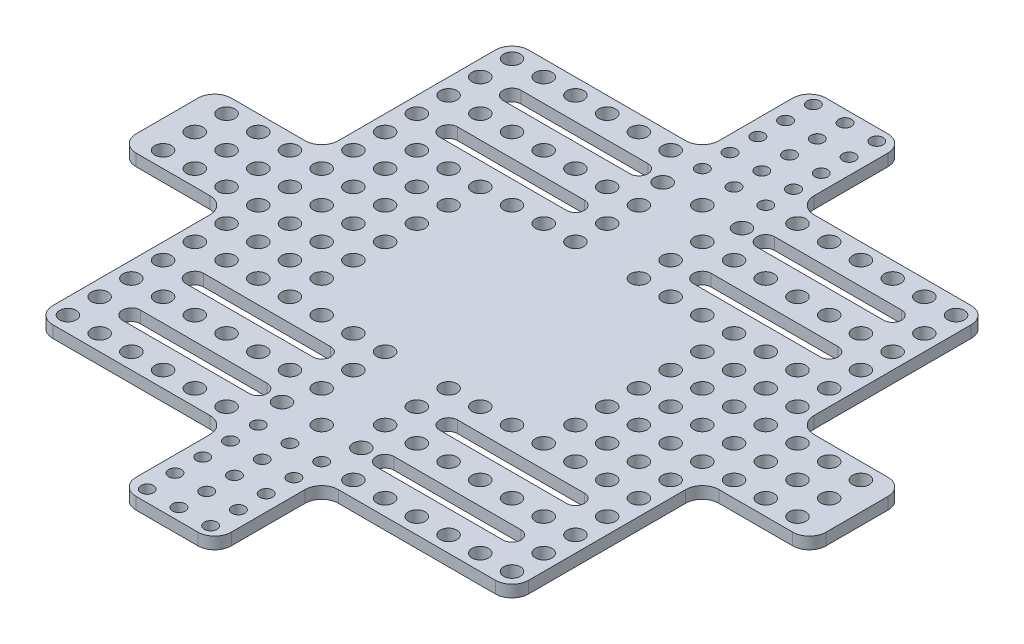
from build123d import *

# Parameters (mm, degrees)
SKETCH_1_R      = 1.6
SKETCH_1_R_2    = 2.1
EXTRUDE_1_DEPTH = 3
FILLET_1_R      = 4.2


with BuildPart() as part:
    # 草图1 → 凸台-拉伸1 (new body)
    with BuildSketch(Plane(origin=(0, 0, 0), x_dir=(1, 0, 0), z_dir=(0, 1, 0))):
        Polygon((87, -12), (60, -12), (60, -60), (12, -60), (12, -87), (-12, -87), (-12, -60), (-60, -60), (-60, -12), (-87, -12), (-87, 12), (-60, 12), (-60, 60), (-12, 60), (-12, 87), (12, 87), (12, 60), (60, 60), (60, 12), (87, 12), align=None)
        with Locations((0, 56)):
            Circle(SKETCH_1_R, mode=Mode.SUBTRACT)
        with Locations((-56, 56)):
            Circle(SKETCH_1_R_2, mode=Mode.SUBTRACT)
        with Locations((-48, 56)):
            Circle(SKETCH_1_R_2, mode=Mode.SUBTRACT)
        with Locations((-40, 56)):
            Circle(SKETCH_1_R_2, mode=Mode.SUBTRACT)
        with Locations((-32, 56)):
            Circle(SKETCH_1_R_2, mode=Mode.SUBTRACT)
        with Locations((-24, 56)):
            Circle(SKETCH_1_R_2, mode=Mode.SUBTRACT)
        with Locations((-16, 56)):
            Circle(SKETCH_1_R_2, mode=Mode.SUBTRACT)
        with Locations((-8, 56)):
            Circle(SKETCH_1_R, mode=Mode.SUBTRACT)
        with Locations((8, 56)):
            Circle(SKETCH_1_R, mode=Mode.SUBTRACT)
        with Locations((0, 63)):
            Circle(SKETCH_1_R, mode=Mode.SUBTRACT)
        with Locations((-8, 63)):
            Circle(SKETCH_1_R, mode=Mode.SUBTRACT)
        with Locations((8, 63)):
            Circle(SKETCH_1_R, mode=Mode.SUBTRACT)
        with Locations((0, 70)):
            Circle(SKETCH_1_R, mode=Mode.SUBTRACT)
        with Locations((-8, 70)):
            Circle(SKETCH_1_R, mode=Mode.SUBTRACT)
        with Locations((8, 70)):
            Circle(SKETCH_1_R, mode=Mode.SUBTRACT)
        with Locations((0, 77)):
            Circle(SKETCH_1_R, mode=Mode.SUBTRACT)
        with Locations((-8, 77)):
            Circle(SKETCH_1_R, mode=Mode.SUBTRACT)
        with Locations((8, 77)):
            Circle(SKETCH_1_R, mode=Mode.SUBTRACT)
        with Locations((0, 84)):
            Circle(SKETCH_1_R, mode=Mode.SUBTRACT)
        with Locations((-8, 84)):
            Circle(SKETCH_1_R, mode=Mode.SUBTRACT)
        with Locations((8, 84)):
            Circle(SKETCH_1_R, mode=Mode.SUBTRACT)
        with Locations((0, 48)):
            Circle(SKETCH_1_R_2, mode=Mode.SUBTRACT)
        with Locations((-10, 48)):
            Circle(SKETCH_1_R_2, mode=Mode.SUBTRACT)
        with Locations((10, 48)):
            Circle(SKETCH_1_R_2, mode=Mode.SUBTRACT)
        with Locations((-56, 16)):
            Circle(SKETCH_1_R_2, mode=Mode.SUBTRACT)
        with Locations((-56, 24)):
            Circle(SKETCH_1_R_2, mode=Mode.SUBTRACT)
        with Locations((-56, 32)):
            Circle(SKETCH_1_R_2, mode=Mode.SUBTRACT)
        with Locations((-56, 40)):
            Circle(SKETCH_1_R_2, mode=Mode.SUBTRACT)
        with Locations((-56, 48)):
            Circle(SKETCH_1_R_2, mode=Mode.SUBTRACT)
        with Locations((-48, 16)):
            Circle(SKETCH_1_R_2, mode=Mode.SUBTRACT)
        with Locations((-40, 16)):
            Circle(SKETCH_1_R_2, mode=Mode.SUBTRACT)
        with Locations((-32, 16)):
            Circle(SKETCH_1_R_2, mode=Mode.SUBTRACT)
        with Locations((-48, 8)):
            Circle(SKETCH_1_R_2, mode=Mode.SUBTRACT)
        with Locations((-40, 8)):
            Circle(SKETCH_1_R_2, mode=Mode.SUBTRACT)
        with Locations((-32, 8)):
            Circle(SKETCH_1_R_2, mode=Mode.SUBTRACT)
        with Locations((-48, 0)):
            Circle(SKETCH_1_R_2, mode=Mode.SUBTRACT)
        with Locations((-40, 0)):
            Circle(SKETCH_1_R_2, mode=Mode.SUBTRACT)
        with Locations((-32, 0)):
            Circle(SKETCH_1_R_2, mode=Mode.SUBTRACT)
        with Locations((-48, -8)):
            Circle(SKETCH_1_R_2, mode=Mode.SUBTRACT)
        with Locations((-40, -8)):
            Circle(SKETCH_1_R_2, mode=Mode.SUBTRACT)
        with Locations((-32, -8)):
            Circle(SKETCH_1_R_2, mode=Mode.SUBTRACT)
        with Locations((-48, -16)):
            Circle(SKETCH_1_R_2, mode=Mode.SUBTRACT)
        with Locations((-40, -16)):
            Circle(SKETCH_1_R_2, mode=Mode.SUBTRACT)
        with Locations((-32, -16)):
            Circle(SKETCH_1_R_2, mode=Mode.SUBTRACT)
        with Locations((-56, 8)):
            Circle(SKETCH_1_R_2, mode=Mode.SUBTRACT)
        with Locations((-56, 0)):
            Circle(SKETCH_1_R_2, mode=Mode.SUBTRACT)
        with Locations((-56, -8)):
            Circle(SKETCH_1_R_2, mode=Mode.SUBTRACT)
        with Locations((-56, -16)):
            Circle(SKETCH_1_R_2, mode=Mode.SUBTRACT)
        with Locations((56, -16)):
            Circle(SKETCH_1_R_2, mode=Mode.SUBTRACT)
        with Locations((56, -8)):
            Circle(SKETCH_1_R_2, mode=Mode.SUBTRACT)
        with Locations((56, 0)):
            Circle(SKETCH_1_R_2, mode=Mode.SUBTRACT)
        with Locations((56, 8)):
            Circle(SKETCH_1_R_2, mode=Mode.SUBTRACT)
        with Locations((32, -16)):
            Circle(SKETCH_1_R_2, mode=Mode.SUBTRACT)
        with Locations((40, -16)):
            Circle(SKETCH_1_R_2, mode=Mode.SUBTRACT)
        with Locations((48, -16)):
            Circle(SKETCH_1_R_2, mode=Mode.SUBTRACT)
        with Locations((32, -8)):
            Circle(SKETCH_1_R_2, mode=Mode.SUBTRACT)
        with Locations((40, -8)):
            Circle(SKETCH_1_R_2, mode=Mode.SUBTRACT)
        with Locations((48, -8)):
            Circle(SKETCH_1_R_2, mode=Mode.SUBTRACT)
        with Locations((32, 0)):
            Circle(SKETCH_1_R_2, mode=Mode.SUBTRACT)
        with Locations((40, 0)):
            Circle(SKETCH_1_R_2, mode=Mode.SUBTRACT)
        with Locations((48, 0)):
            Circle(SKETCH_1_R_2, mode=Mode.SUBTRACT)
        with Locations((32, 8)):
            Circle(SKETCH_1_R_2, mode=Mode.SUBTRACT)
        with Locations((40, 8)):
            Circle(SKETCH_1_R_2, mode=Mode.SUBTRACT)
        with Locations((48, 8)):
            Circle(SKETCH_1_R_2, mode=Mode.SUBTRACT)
        with Locations((32, 16)):
            Circle(SKETCH_1_R_2, mode=Mode.SUBTRACT)
        with Locations((40, 16)):
            Circle(SKETCH_1_R_2, mode=Mode.SUBTRACT)
        with Locations((48, 16)):
            Circle(SKETCH_1_R_2, mode=Mode.SUBTRACT)
        with Locations((56, 16)):
            Circle(SKETCH_1_R_2, mode=Mode.SUBTRACT)
        with Locations((-48, 40)):
            Circle(SKETCH_1_R_2, mode=Mode.SUBTRACT)
        with Locations((-40, 40)):
            Circle(SKETCH_1_R_2, mode=Mode.SUBTRACT)
        with Locations((-32, 40)):
            Circle(SKETCH_1_R_2, mode=Mode.SUBTRACT)
        with Locations((-24, 40)):
            Circle(SKETCH_1_R_2, mode=Mode.SUBTRACT)
        with Locations((-16, 40)):
            Circle(SKETCH_1_R_2, mode=Mode.SUBTRACT)
        with Locations((-8, 40)):
            Circle(SKETCH_1_R_2, mode=Mode.SUBTRACT)
        with Locations((-16, 24)):
            Circle(SKETCH_1_R_2, mode=Mode.SUBTRACT)
        with Locations((-24, 24)):
            Circle(SKETCH_1_R_2, mode=Mode.SUBTRACT)
        with Locations((-32, 24)):
            Circle(SKETCH_1_R_2, mode=Mode.SUBTRACT)
        with Locations((-48, 24)):
            Circle(SKETCH_1_R_2, mode=Mode.SUBTRACT)
        with Locations((-40, 24)):
            Circle(SKETCH_1_R_2, mode=Mode.SUBTRACT)
        with Locations((-8, 24)):
            Circle(SKETCH_1_R_2, mode=Mode.SUBTRACT)
        with Locations((8, 24)):
            Circle(SKETCH_1_R_2, mode=Mode.SUBTRACT)
        with Locations((16, 24)):
            Circle(SKETCH_1_R_2, mode=Mode.SUBTRACT)
        with Locations((24, 24)):
            Circle(SKETCH_1_R_2, mode=Mode.SUBTRACT)
        with Locations((32, 24)):
            Circle(SKETCH_1_R_2, mode=Mode.SUBTRACT)
        with Locations((40, 24)):
            Circle(SKETCH_1_R_2, mode=Mode.SUBTRACT)
        with Locations((48, 24)):
            Circle(SKETCH_1_R_2, mode=Mode.SUBTRACT)
        with Locations((56, 24)):
            Circle(SKETCH_1_R_2, mode=Mode.SUBTRACT)
        with Locations((56, 32)):
            Circle(SKETCH_1_R_2, mode=Mode.SUBTRACT)
        with Locations((8, 40)):
            Circle(SKETCH_1_R_2, mode=Mode.SUBTRACT)
        with Locations((16, 40)):
            Circle(SKETCH_1_R_2, mode=Mode.SUBTRACT)
        with Locations((24, 40)):
            Circle(SKETCH_1_R_2, mode=Mode.SUBTRACT)
        with Locations((32, 40)):
            Circle(SKETCH_1_R_2, mode=Mode.SUBTRACT)
        with Locations((40, 40)):
            Circle(SKETCH_1_R_2, mode=Mode.SUBTRACT)
        with Locations((48, 40)):
            Circle(SKETCH_1_R_2, mode=Mode.SUBTRACT)
        with Locations((56, 40)):
            Circle(SKETCH_1_R_2, mode=Mode.SUBTRACT)
        with Locations((56, 48)):
            Circle(SKETCH_1_R_2, mode=Mode.SUBTRACT)
        with Locations((16, 56)):
            Circle(SKETCH_1_R_2, mode=Mode.SUBTRACT)
        with Locations((24, 56)):
            Circle(SKETCH_1_R_2, mode=Mode.SUBTRACT)
        with Locations((32, 56)):
            Circle(SKETCH_1_R_2, mode=Mode.SUBTRACT)
        with Locations((40, 56)):
            Circle(SKETCH_1_R_2, mode=Mode.SUBTRACT)
        with Locations((48, 56)):
            Circle(SKETCH_1_R_2, mode=Mode.SUBTRACT)
        with Locations((56, 56)):
            Circle(SKETCH_1_R_2, mode=Mode.SUBTRACT)
        with Locations((8, -77)):
            Circle(SKETCH_1_R, mode=Mode.SUBTRACT)
        with Locations((8, -84)):
            Circle(SKETCH_1_R, mode=Mode.SUBTRACT)
        with Locations((0, -84)):
            Circle(SKETCH_1_R, mode=Mode.SUBTRACT)
        with Locations((-8, -84)):
            Circle(SKETCH_1_R, mode=Mode.SUBTRACT)
        with Locations((-8, -77)):
            Circle(SKETCH_1_R, mode=Mode.SUBTRACT)
        with Locations((0, -77)):
            Circle(SKETCH_1_R, mode=Mode.SUBTRACT)
        with Locations((8, -70)):
            Circle(SKETCH_1_R, mode=Mode.SUBTRACT)
        with Locations((0, -70)):
            Circle(SKETCH_1_R, mode=Mode.SUBTRACT)
        with Locations((-8, -70)):
            Circle(SKETCH_1_R, mode=Mode.SUBTRACT)
        with Locations((-8, -63)):
            Circle(SKETCH_1_R, mode=Mode.SUBTRACT)
        with Locations((0, -63)):
            Circle(SKETCH_1_R, mode=Mode.SUBTRACT)
        with Locations((8, -63)):
            Circle(SKETCH_1_R, mode=Mode.SUBTRACT)
        with Locations((24, -56)):
            Circle(SKETCH_1_R_2, mode=Mode.SUBTRACT)
        with Locations((16, -56)):
            Circle(SKETCH_1_R_2, mode=Mode.SUBTRACT)
        with Locations((8, -56)):
            Circle(SKETCH_1_R, mode=Mode.SUBTRACT)
        with Locations((0, -56)):
            Circle(SKETCH_1_R, mode=Mode.SUBTRACT)
        with Locations((-8, -56)):
            Circle(SKETCH_1_R, mode=Mode.SUBTRACT)
        with Locations((-16, -56)):
            Circle(SKETCH_1_R_2, mode=Mode.SUBTRACT)
        with Locations((-24, -56)):
            Circle(SKETCH_1_R_2, mode=Mode.SUBTRACT)
        with Locations((-32, -56)):
            Circle(SKETCH_1_R_2, mode=Mode.SUBTRACT)
        with Locations((-40, -56)):
            Circle(SKETCH_1_R_2, mode=Mode.SUBTRACT)
        with Locations((-48, -56)):
            Circle(SKETCH_1_R_2, mode=Mode.SUBTRACT)
        with Locations((-56, -56)):
            Circle(SKETCH_1_R_2, mode=Mode.SUBTRACT)
        with Locations((-56, -48)):
            Circle(SKETCH_1_R_2, mode=Mode.SUBTRACT)
        with Locations((10, -48)):
            Circle(SKETCH_1_R_2, mode=Mode.SUBTRACT)
        with Locations((0, -48)):
            Circle(SKETCH_1_R_2, mode=Mode.SUBTRACT)
        with Locations((-10, -48)):
            Circle(SKETCH_1_R_2, mode=Mode.SUBTRACT)
        with Locations((32, -56)):
            Circle(SKETCH_1_R_2, mode=Mode.SUBTRACT)
        with Locations((40, -56)):
            Circle(SKETCH_1_R_2, mode=Mode.SUBTRACT)
        with Locations((48, -56)):
            Circle(SKETCH_1_R_2, mode=Mode.SUBTRACT)
        with Locations((56, -56)):
            Circle(SKETCH_1_R_2, mode=Mode.SUBTRACT)
        with Locations((56, -48)):
            Circle(SKETCH_1_R_2, mode=Mode.SUBTRACT)
        with Locations((56, -40)):
            Circle(SKETCH_1_R_2, mode=Mode.SUBTRACT)
        with Locations((48, -40)):
            Circle(SKETCH_1_R_2, mode=Mode.SUBTRACT)
        with Locations((40, -40)):
            Circle(SKETCH_1_R_2, mode=Mode.SUBTRACT)
        with Locations((32, -40)):
            Circle(SKETCH_1_R_2, mode=Mode.SUBTRACT)
        with Locations((24, -40)):
            Circle(SKETCH_1_R_2, mode=Mode.SUBTRACT)
        with Locations((16, -40)):
            Circle(SKETCH_1_R_2, mode=Mode.SUBTRACT)
        with Locations((8, -40)):
            Circle(SKETCH_1_R_2, mode=Mode.SUBTRACT)
        with Locations((-8, -40)):
            Circle(SKETCH_1_R_2, mode=Mode.SUBTRACT)
        with Locations((-16, -40)):
            Circle(SKETCH_1_R_2, mode=Mode.SUBTRACT)
        with Locations((-24, -40)):
            Circle(SKETCH_1_R_2, mode=Mode.SUBTRACT)
        with Locations((-32, -40)):
            Circle(SKETCH_1_R_2, mode=Mode.SUBTRACT)
        with Locations((-40, -40)):
            Circle(SKETCH_1_R_2, mode=Mode.SUBTRACT)
        with Locations((-48, -40)):
            Circle(SKETCH_1_R_2, mode=Mode.SUBTRACT)
        with Locations((-56, -40)):
            Circle(SKETCH_1_R_2, mode=Mode.SUBTRACT)
        with Locations((-56, -32)):
            Circle(SKETCH_1_R_2, mode=Mode.SUBTRACT)
        with Locations((56, -32)):
            Circle(SKETCH_1_R_2, mode=Mode.SUBTRACT)
        with Locations((56, -24)):
            Circle(SKETCH_1_R_2, mode=Mode.SUBTRACT)
        with Locations((48, -24)):
            Circle(SKETCH_1_R_2, mode=Mode.SUBTRACT)
        with Locations((40, -24)):
            Circle(SKETCH_1_R_2, mode=Mode.SUBTRACT)
        with Locations((32, -24)):
            Circle(SKETCH_1_R_2, mode=Mode.SUBTRACT)
        with Locations((24, -24)):
            Circle(SKETCH_1_R_2, mode=Mode.SUBTRACT)
        with Locations((16, -24)):
            Circle(SKETCH_1_R_2, mode=Mode.SUBTRACT)
        with Locations((8, -24)):
            Circle(SKETCH_1_R_2, mode=Mode.SUBTRACT)
        with Locations((-8, -24)):
            Circle(SKETCH_1_R_2, mode=Mode.SUBTRACT)
        with Locations((-16, -24)):
            Circle(SKETCH_1_R_2, mode=Mode.SUBTRACT)
        with Locations((-24, -24)):
            Circle(SKETCH_1_R_2, mode=Mode.SUBTRACT)
        with Locations((-32, -24)):
            Circle(SKETCH_1_R_2, mode=Mode.SUBTRACT)
        with Locations((-40, -24)):
            Circle(SKETCH_1_R_2, mode=Mode.SUBTRACT)
        with Locations((-48, -24)):
            Circle(SKETCH_1_R_2, mode=Mode.SUBTRACT)
        with Locations((-56, -24)):
            Circle(SKETCH_1_R_2, mode=Mode.SUBTRACT)
        with Locations((-64, 8)):
            Circle(SKETCH_1_R_2, mode=Mode.SUBTRACT)
        with Locations((-64, 0)):
            Circle(SKETCH_1_R_2, mode=Mode.SUBTRACT)
        with Locations((-64, -8)):
            Circle(SKETCH_1_R_2, mode=Mode.SUBTRACT)
        with Locations((-72, 8)):
            Circle(SKETCH_1_R_2, mode=Mode.SUBTRACT)
        with Locations((-72, 0)):
            Circle(SKETCH_1_R_2, mode=Mode.SUBTRACT)
        with Locations((-72, -8)):
            Circle(SKETCH_1_R_2, mode=Mode.SUBTRACT)
        with Locations((-80, 8)):
            Circle(SKETCH_1_R_2, mode=Mode.SUBTRACT)
        with Locations((-80, 0)):
            Circle(SKETCH_1_R_2, mode=Mode.SUBTRACT)
        with Locations((-80, -8)):
            Circle(SKETCH_1_R_2, mode=Mode.SUBTRACT)
        with Locations((80, -8)):
            Circle(SKETCH_1_R_2, mode=Mode.SUBTRACT)
        with Locations((80, 0)):
            Circle(SKETCH_1_R_2, mode=Mode.SUBTRACT)
        with Locations((80, 8)):
            Circle(SKETCH_1_R_2, mode=Mode.SUBTRACT)
        with Locations((72, -8)):
            Circle(SKETCH_1_R_2, mode=Mode.SUBTRACT)
        with Locations((72, 0)):
            Circle(SKETCH_1_R_2, mode=Mode.SUBTRACT)
        with Locations((72, 8)):
            Circle(SKETCH_1_R_2, mode=Mode.SUBTRACT)
        with Locations((64, -8)):
            Circle(SKETCH_1_R_2, mode=Mode.SUBTRACT)
        with Locations((64, 0)):
            Circle(SKETCH_1_R_2, mode=Mode.SUBTRACT)
        with Locations((64, 8)):
            Circle(SKETCH_1_R_2, mode=Mode.SUBTRACT)
        with Locations((-8, 32)):
            Circle(SKETCH_1_R_2, mode=Mode.SUBTRACT)
        with Locations((8, 32)):
            Circle(SKETCH_1_R_2, mode=Mode.SUBTRACT)
        with Locations((8, -32)):
            Circle(SKETCH_1_R_2, mode=Mode.SUBTRACT)
        with Locations((-8, -32)):
            Circle(SKETCH_1_R_2, mode=Mode.SUBTRACT)
        with BuildLine():
            Line((-48, 50.25), (-16, 50.25))
            ThreePointArc((-16, 50.25), (-13.75, 48), (-16, 45.75))
            Line((-16, 45.75), (-48, 45.75))
            ThreePointArc((-48, 45.75), (-50.25, 48), (-48, 50.25))
        make_face(mode=Mode.SUBTRACT)
        with BuildLine():
            Line((-48, 34.25), (-16, 34.25))
            ThreePointArc((-16, 34.25), (-13.75, 32), (-16, 29.75))
            Line((-16, 29.75), (-48, 29.75))
            ThreePointArc((-48, 29.75), (-50.25, 32), (-48, 34.25))
        make_face(mode=Mode.SUBTRACT)
        with BuildLine():
            Line((48, 34.25), (16, 34.25))
            ThreePointArc((16, 34.25), (13.75, 32), (16, 29.75))
            Line((16, 29.75), (48, 29.75))
            ThreePointArc((48, 29.75), (50.25, 32), (48, 34.25))
        make_face(mode=Mode.SUBTRACT)
        with BuildLine():
            Line((48, 50.25), (16, 50.25))
            ThreePointArc((16, 50.25), (13.75, 48), (16, 45.75))
            Line((16, 45.75), (48, 45.75))
            ThreePointArc((48, 45.75), (50.25, 48), (48, 50.25))
        make_face(mode=Mode.SUBTRACT)
        with BuildLine():
            Line((-48, -50.25), (-16, -50.25))
            ThreePointArc((-16, -50.25), (-13.75, -48), (-16, -45.75))
            Line((-16, -45.75), (-48, -45.75))
            ThreePointArc((-48, -45.75), (-50.25, -48), (-48, -50.25))
        make_face(mode=Mode.SUBTRACT)
        with BuildLine():
            Line((48, -50.25), (16, -50.25))
            ThreePointArc((16, -50.25), (13.75, -48), (16, -45.75))
            Line((16, -45.75), (48, -45.75))
            ThreePointArc((48, -45.75), (50.25, -48), (48, -50.25))
        make_face(mode=Mode.SUBTRACT)
        with BuildLine():
            Line((-48, -34.25), (-16, -34.25))
            ThreePointArc((-16, -34.25), (-13.75, -32), (-16, -29.75))
            Line((-16, -29.75), (-48, -29.75))
            ThreePointArc((-48, -29.75), (-50.25, -32), (-48, -34.25))
        make_face(mode=Mode.SUBTRACT)
        with BuildLine():
            Line((48, -34.25), (16, -34.25))
            ThreePointArc((16, -34.25), (13.75, -32), (16, -29.75))
            Line((16, -29.75), (48, -29.75))
            ThreePointArc((48, -29.75), (50.25, -32), (48, -34.25))
        make_face(mode=Mode.SUBTRACT)
    extrude(amount=EXTRUDE_1_DEPTH)

    # 圆角1
    fillet_1_edges = [part.edges().sort_by_distance(p)[0] for p in [
        (12, 1.5, 60),
        (12, 1.5, 87),
        (-12, 1.5, 87),
        (-12, 1.5, 60),
        (-60, 1.5, 60),
        (-60, 1.5, 12),
        (-87, 1.5, 12),
        (-87, 1.5, -12),
        (-60, 1.5, -12),
        (-60, 1.5, -60),
        (-12, 1.5, -60),
        (-12, 1.5, -87),
        (12, 1.5, -87),
        (12, 1.5, -60),
        (60, 1.5, -60),
        (60, 1.5, -12),
        (87, 1.5, -12),
        (87, 1.5, 12),
        (60, 1.5, 12),
        (60, 1.5, 60),
    ]]
    fillet(fillet_1_edges, radius=FILLET_1_R)


solid = part.part
